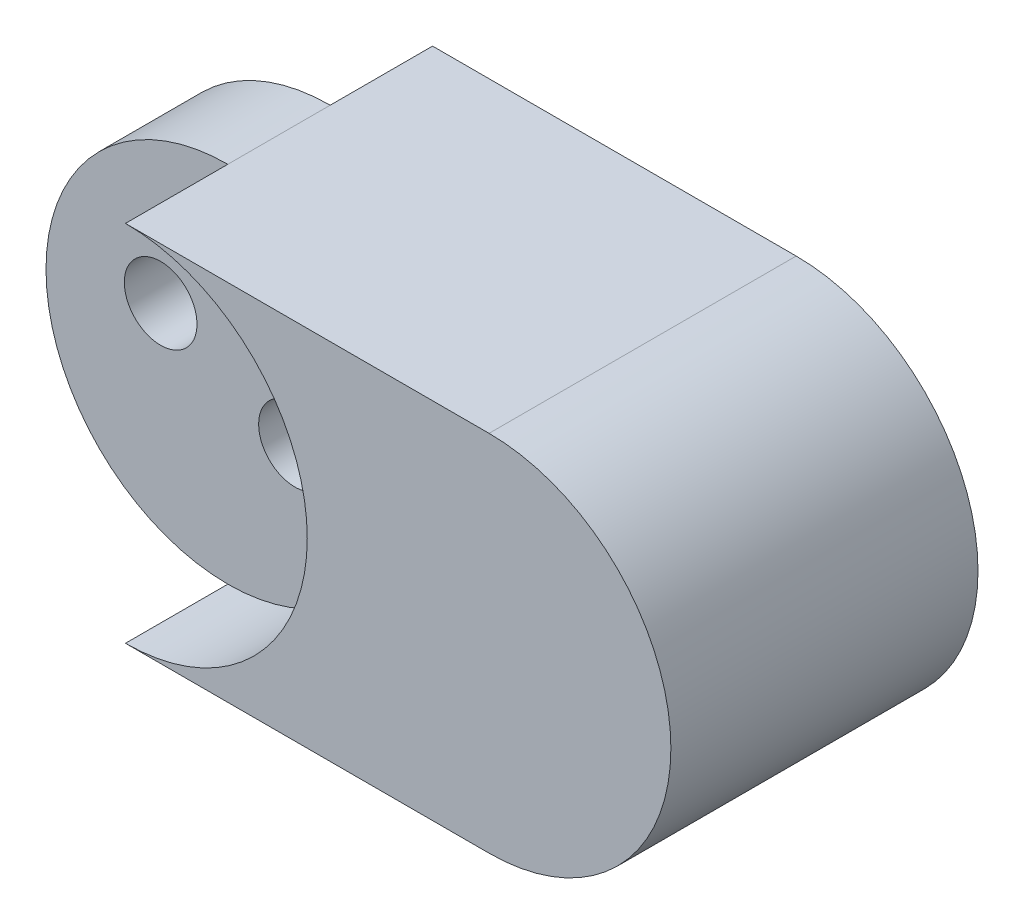
from build123d import *

# Parameters (mm, degrees)
SKETCH1_R           = 0.8875
BOSS_EXTRUDE1_DEPTH = 7.5
SKETCH2_R           = 4.44
CUT_EXTRUDE1_DEPTH  = 2.5
CUT_EXTRUDE2_START  = -5
SKETCH2_2_R         = 4.44
CUT_EXTRUDE2_DEPTH  = 2.5


with BuildPart() as part:
    # Sketch1 → Boss-Extrude1 (new body)
    with BuildSketch(Plane.XY):
        with BuildLine():
            Line((-1.63988617, 5.119263092), (7.24011383, 5.119263092))
            ThreePointArc((7.24011383, 5.119263092), (11.68011383, 0.679263092), (7.24011383, -3.760736908))
            Line((7.24011383, -3.760736908), (-1.63988617, -3.760736908))
            ThreePointArc((-1.63988617, -3.760736908), (-6.07988617, 0.679263092), (-1.63988617, 5.119263092))
        make_face()
        Circle(SKETCH1_R, mode=Mode.SUBTRACT)
        with Locations((-3.27977234, 1.358526185)):
            Circle(SKETCH1_R, mode=Mode.SUBTRACT)
    extrude(amount=BOSS_EXTRUDE1_DEPTH)

    # Sketch2 → Cut-Extrude1 (cut)
    with BuildSketch(Plane(origin=(0, 0, 0), x_dir=(-1, 0, 0), z_dir=(0, 0, -1))):
        with Locations((1.63988617, 0.679263092)):
            Circle(SKETCH2_R)
    extrude(amount=-CUT_EXTRUDE1_DEPTH, mode=Mode.SUBTRACT)

    # Sketch2_2 → Cut-Extrude2 (cut)
    with BuildSketch(Plane(origin=(0, 0, 0), x_dir=(-1, 0, 0), z_dir=(0, 0, -1)).offset(CUT_EXTRUDE2_START)):
        with Locations((1.63988617, 0.679263092)):
            Circle(SKETCH2_2_R)
    extrude(amount=-CUT_EXTRUDE2_DEPTH, mode=Mode.SUBTRACT)


solid = part.part
